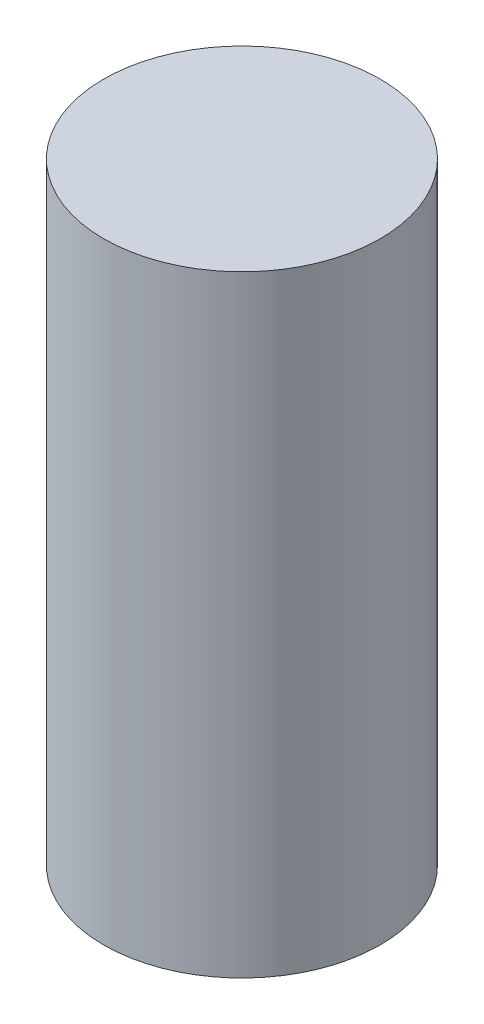
from build123d import *

# Parameters (mm, degrees)
SKETCH1_R           = 2.6
BOSS_EXTRUDE1_DEPTH = 11.5


with BuildPart() as part:
    # Sketch1 → Boss-Extrude1 (new body)
    with BuildSketch(Plane(origin=(0, 0, 0), x_dir=(1, 0, 0), z_dir=(0, 1, 0))):
        Circle(SKETCH1_R)
    extrude(amount=BOSS_EXTRUDE1_DEPTH)


solid = part.part
